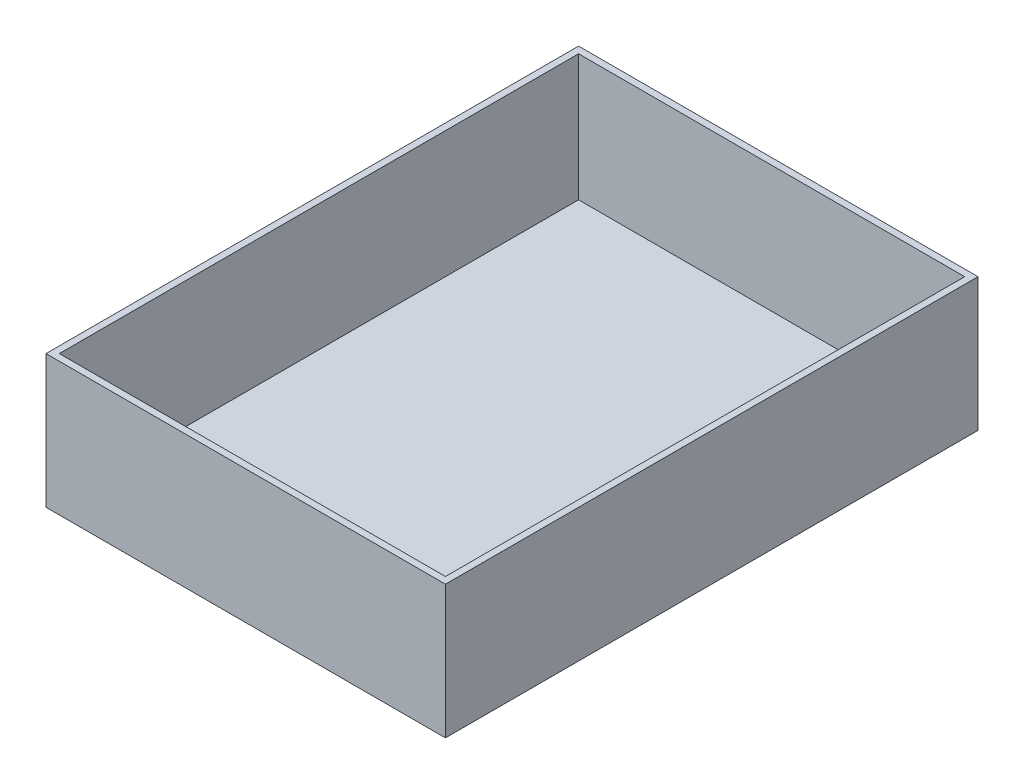
from build123d import *

# Parameters (mm, degrees)
SKETCH2_W           = 150
SKETCH2_H           = 50
BOSS_EXTRUDE1_DEPTH = 200
SKETCH4_W           = 145
SKETCH4_H           = 195
CUT_EXTRUDE1_DEPTH  = 47.5


with BuildPart() as part:
    # Sketch2 → Boss-Extrude1 (new body)
    with BuildSketch(Plane.XY):
        Rectangle(SKETCH2_W, SKETCH2_H)
    extrude(amount=-BOSS_EXTRUDE1_DEPTH)

    # Sketch4 → Cut-Extrude1 (cut)
    with BuildSketch(Plane(origin=(0, 25, 0), x_dir=(1, 0, 0), z_dir=(0, 1, 0))):
        with Locations((0, 100)):
            Rectangle(SKETCH4_W, SKETCH4_H)
    extrude(amount=-CUT_EXTRUDE1_DEPTH, mode=Mode.SUBTRACT)


solid = part.part
